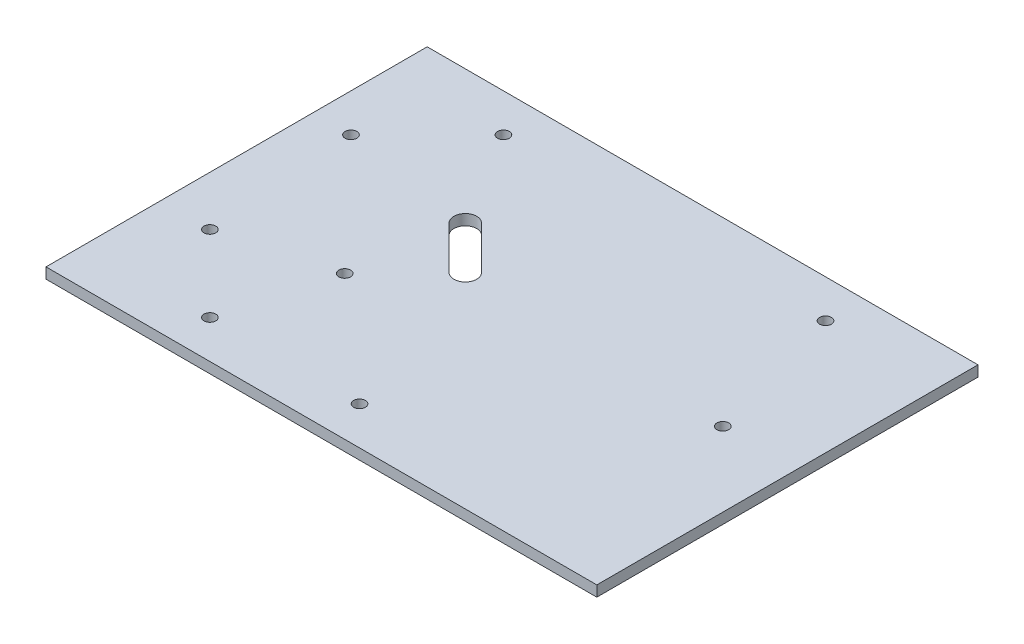
from build123d import *

# Parameters (mm, degrees)
SKETCH1_W           = 144.5
SKETCH1_H           = 100
SKETCH1_R           = 1.55
BOSS_EXTRUDE1_DEPTH = 2.8
CUT_EXTRUDE1_REACH  = 4.8
CUT_EXTRUDE2_REACH  = 4.8
SKETCH3_R           = 1.55
CUT_EXTRUDE3_REACH  = 4.8
SKETCH4_R           = 1.55


with BuildPart() as part:
    # Sketch1 → Boss-Extrude1 (new body)
    with BuildSketch(Plane(origin=(0, 0, 0), x_dir=(1, 0, 0), z_dir=(0, 1, 0))):
        Rectangle(SKETCH1_W, SKETCH1_H)
        with Locations((-59.25, -20)):
            Circle(SKETCH1_R, mode=Mode.SUBTRACT)
        with Locations((-39.25, -40)):
            Circle(SKETCH1_R, mode=Mode.SUBTRACT)
        with Locations((-31.57233047, -12.32233047)):
            Circle(SKETCH1_R, mode=Mode.SUBTRACT)
    extrude(amount=BOSS_EXTRUDE1_DEPTH)

    # Sketch2 → Cut-Extrude1 (cut, up to next)
    with BuildSketch(Plane(origin=(0, 2.8, 0), x_dir=(1, 0, 0), z_dir=(0, 1, 0)), mode=Mode.PRIVATE) as cut_extrude1_sk1:
        with BuildLine():
            Line((-25.128679656, 17.121320344), (-13.814971157, 5.807611845))
            ThreePointArc((-13.814971157, 5.807611845), (-13.814971157, 1.564971157), (-18.057611845, 1.564971157))
            Line((-18.057611845, 1.564971157), (-29.371320344, 12.878679656))
            ThreePointArc((-29.371320344, 12.878679656), (-29.371320344, 17.121320344), (-25.128679656, 17.121320344))
        make_face()
    cut_extrude1_tool1 = extrude(cut_extrude1_sk1.sketch, amount=-CUT_EXTRUDE1_REACH, mode=Mode.PRIVATE) & part.part
    add(cut_extrude1_tool1.solids().sort_by_distance((-21.593146, 2.8, -9.343146))[0], mode=Mode.SUBTRACT)

    # Sketch3 → Cut-Extrude2 (cut, up to next)
    with BuildSketch(Plane(origin=(0, 2.8, 0), x_dir=(1, 0, 0), z_dir=(0, 1, 0)), mode=Mode.PRIVATE) as cut_extrude2_sk1:
        with Locations((-62.25, 20)):
            Circle(SKETCH3_R)
    cut_extrude2_tool1 = extrude(cut_extrude2_sk1.sketch, amount=-CUT_EXTRUDE2_REACH, mode=Mode.PRIVATE) & part.part
    add(cut_extrude2_tool1.solids().sort_by_distance((-62.25, 2.8, -20))[0], mode=Mode.SUBTRACT)
    # Sketch3 → Cut-Extrude2 (cut, up to next)
    with BuildSketch(Plane(origin=(0, 2.8, 0), x_dir=(1, 0, 0), z_dir=(0, 1, 0)), mode=Mode.PRIVATE) as cut_extrude2_sk2:
        with Locations((-42.25, 40)):
            Circle(SKETCH3_R)
    cut_extrude2_tool2 = extrude(cut_extrude2_sk2.sketch, amount=-CUT_EXTRUDE2_REACH, mode=Mode.PRIVATE) & part.part
    add(cut_extrude2_tool2.solids().sort_by_distance((-42.25, 2.8, -40))[0], mode=Mode.SUBTRACT)
    # Sketch3 → Cut-Extrude2 (cut, up to next)
    with BuildSketch(Plane(origin=(0, 2.8, 0), x_dir=(1, 0, 0), z_dir=(0, 1, 0)), mode=Mode.PRIVATE) as cut_extrude2_sk3:
        with Locations((42.25, 40)):
            Circle(SKETCH3_R)
    cut_extrude2_tool3 = extrude(cut_extrude2_sk3.sketch, amount=-CUT_EXTRUDE2_REACH, mode=Mode.PRIVATE) & part.part
    add(cut_extrude2_tool3.solids().sort_by_distance((42.25, 2.8, -40))[0], mode=Mode.SUBTRACT)
    # Sketch3 → Cut-Extrude2 (cut, up to next)
    with BuildSketch(Plane(origin=(0, 2.8, 0), x_dir=(1, 0, 0), z_dir=(0, 1, 0)), mode=Mode.PRIVATE) as cut_extrude2_sk4:
        with Locations((0, -40)):
            Circle(SKETCH3_R)
    cut_extrude2_tool4 = extrude(cut_extrude2_sk4.sketch, amount=-CUT_EXTRUDE2_REACH, mode=Mode.PRIVATE) & part.part
    add(cut_extrude2_tool4.solids().sort_by_distance((0, 2.8, 40))[0], mode=Mode.SUBTRACT)

    # Sketch4 → Cut-Extrude3 (cut, up to next)
    with BuildSketch(Plane(origin=(0, 2.8, 0), x_dir=(1, 0, 0), z_dir=(0, 1, 0)), mode=Mode.PRIVATE) as cut_extrude3_sk1:
        with Locations((52.75, 2.56)):
            Circle(SKETCH4_R)
    cut_extrude3_tool1 = extrude(cut_extrude3_sk1.sketch, amount=-CUT_EXTRUDE3_REACH, mode=Mode.PRIVATE) & part.part
    add(cut_extrude3_tool1.solids().sort_by_distance((52.75, 2.8, -2.56))[0], mode=Mode.SUBTRACT)


solid = part.part
